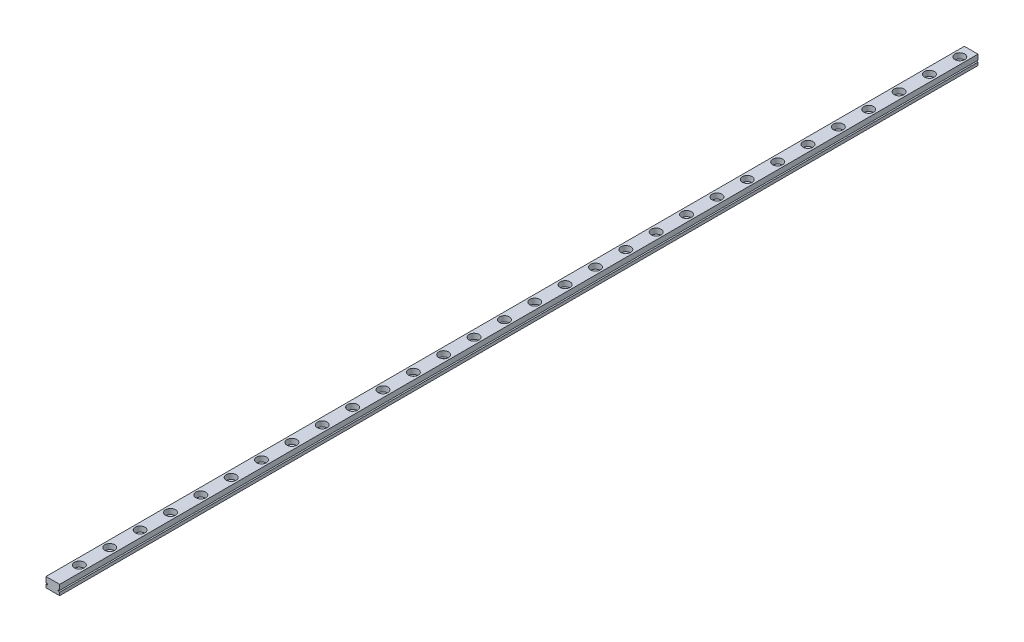
from build123d import *

# Parameters (mm, degrees)
SKETCH_1_W          = 9
SKETCH_1_H          = 6.5
EXTRUDE_1_DEPTH     = 608
SKETCH_2_R          = 1.75
CUT_EXTRUDE_1_DEPTH = 7.5
SKETCH_3_R          = 3.25
CUT_EXTRUDE_2_DEPTH = 3.5
CUT_EXTRUDE_3_DEPTH = 609
SKETCH_5_R          = 3.25
CUT_EXTRUDE_4_DEPTH = 3.5
SKETCH_6_R          = 1.75
CUT_EXTRUDE_5_DEPTH = 4
SKETCH_7_W          = 9
SKETCH_7_H          = 3
CUT_EXTRUDE_6_DEPTH = 7.5


with BuildPart() as part:
    # 草图1 → 凸台-拉伸1 (new body)
    with BuildSketch(Plane.XY):
        Rectangle(SKETCH_1_W, SKETCH_1_H)
    extrude(amount=EXTRUDE_1_DEPTH)

    # 草图2 → 切除-拉伸1 (cut, through all)
    with BuildSketch(Plane(origin=(0, 3.25, 0), x_dir=(1, 0, 0), z_dir=(0, 1, 0))):
        with Locations((0, -7.5)):
            Circle(SKETCH_2_R)
        with Locations((0, -27.5)):
            Circle(SKETCH_2_R)
        with Locations((0, -47.5)):
            Circle(SKETCH_2_R)
        with Locations((0, -67.5)):
            Circle(SKETCH_2_R)
        with Locations((0, -87.5)):
            Circle(SKETCH_2_R)
        with Locations((0, -107.5)):
            Circle(SKETCH_2_R)
        with Locations((0, -127.5)):
            Circle(SKETCH_2_R)
        with Locations((0, -147.5)):
            Circle(SKETCH_2_R)
        with Locations((0, -167.5)):
            Circle(SKETCH_2_R)
        with Locations((0, -187.5)):
            Circle(SKETCH_2_R)
        with Locations((0, -207.5)):
            Circle(SKETCH_2_R)
        with Locations((0, -227.5)):
            Circle(SKETCH_2_R)
        with Locations((0, -247.5)):
            Circle(SKETCH_2_R)
        with Locations((0, -267.5)):
            Circle(SKETCH_2_R)
        with Locations((0, -287.5)):
            Circle(SKETCH_2_R)
        with Locations((0, -307.5)):
            Circle(SKETCH_2_R)
        with Locations((0, -327.5)):
            Circle(SKETCH_2_R)
        with Locations((0, -347.5)):
            Circle(SKETCH_2_R)
        with Locations((0, -367.5)):
            Circle(SKETCH_2_R)
        with Locations((0, -387.5)):
            Circle(SKETCH_2_R)
    extrude(amount=-CUT_EXTRUDE_1_DEPTH, mode=Mode.SUBTRACT)

    # 草图3 → 切除-拉伸2 (cut)
    with BuildSketch(Plane(origin=(0, 3.25, 0), x_dir=(1, 0, 0), z_dir=(0, 1, 0))):
        with Locations((0, -7.5)):
            Circle(SKETCH_3_R)
        with Locations((0, -27.5)):
            Circle(SKETCH_3_R)
        with Locations((0, -47.5)):
            Circle(SKETCH_3_R)
        with Locations((0, -67.5)):
            Circle(SKETCH_3_R)
        with Locations((0, -87.5)):
            Circle(SKETCH_3_R)
        with Locations((0, -107.5)):
            Circle(SKETCH_3_R)
        with Locations((0, -127.5)):
            Circle(SKETCH_3_R)
        with Locations((0, -147.5)):
            Circle(SKETCH_3_R)
        with Locations((0, -167.5)):
            Circle(SKETCH_3_R)
        with Locations((0, -187.5)):
            Circle(SKETCH_3_R)
        with Locations((0, -207.5)):
            Circle(SKETCH_3_R)
        with Locations((0, -227.5)):
            Circle(SKETCH_3_R)
        with Locations((0, -247.5)):
            Circle(SKETCH_3_R)
        with Locations((0, -267.5)):
            Circle(SKETCH_3_R)
        with Locations((0, -287.5)):
            Circle(SKETCH_3_R)
        with Locations((0, -307.5)):
            Circle(SKETCH_3_R)
        with Locations((0, -327.5)):
            Circle(SKETCH_3_R)
        with Locations((0, -347.5)):
            Circle(SKETCH_3_R)
        with Locations((0, -367.5)):
            Circle(SKETCH_3_R)
        with Locations((0, -387.5)):
            Circle(SKETCH_3_R)
    extrude(amount=-CUT_EXTRUDE_2_DEPTH, mode=Mode.SUBTRACT)

    # 草图4 → 切除-拉伸3 (cut, through all)
    with BuildSketch(Plane(origin=(0, 0, 0), x_dir=(-1, 0, 0), z_dir=(0, 0, -1))):
        Polygon((4.5, -0.25), (3.5, -0.45), (3.5, -1.05), (4.5, -1.25), align=None)
        Polygon((-4.5, -0.25), (-3.5, -0.45), (-3.5, -1.05), (-4.5, -1.25), align=None)
    extrude(amount=-CUT_EXTRUDE_3_DEPTH, mode=Mode.SUBTRACT)

    # 草图5 → 切除-拉伸4 (cut)
    with BuildSketch(Plane(origin=(0, 3.25, 0), x_dir=(1, 0, 0), z_dir=(0, 1, 0))):
        with Locations((0, -407.5)):
            Circle(SKETCH_5_R)
        with Locations((0, -427.5)):
            Circle(SKETCH_5_R)
        with Locations((0, -447.5)):
            Circle(SKETCH_5_R)
        with Locations((0, -467.5)):
            Circle(SKETCH_5_R)
        with Locations((0, -487.5)):
            Circle(SKETCH_5_R)
        with Locations((0, -507.5)):
            Circle(SKETCH_5_R)
        with Locations((0, -527.5)):
            Circle(SKETCH_5_R)
        with Locations((0, -547.5)):
            Circle(SKETCH_5_R)
        with Locations((0, -567.5)):
            Circle(SKETCH_5_R)
        with Locations((0, -587.5)):
            Circle(SKETCH_5_R)
    extrude(amount=-CUT_EXTRUDE_4_DEPTH, mode=Mode.SUBTRACT)

    # 草图6 → 切除-拉伸5 (cut, through all)
    with BuildSketch(Plane(origin=(0, -0.25, 0), x_dir=(1, 0, 0), z_dir=(0, 1, 0))):
        with Locations((0, -407.5)):
            Circle(SKETCH_6_R)
        with Locations((0, -427.5)):
            Circle(SKETCH_6_R)
        with Locations((0, -447.5)):
            Circle(SKETCH_6_R)
        with Locations((0, -467.5)):
            Circle(SKETCH_6_R)
        with Locations((0, -487.5)):
            Circle(SKETCH_6_R)
        with Locations((0, -507.5)):
            Circle(SKETCH_6_R)
        with Locations((0, -527.5)):
            Circle(SKETCH_6_R)
        with Locations((0, -547.5)):
            Circle(SKETCH_6_R)
        with Locations((0, -567.5)):
            Circle(SKETCH_6_R)
        with Locations((0, -587.5)):
            Circle(SKETCH_6_R)
    extrude(amount=-CUT_EXTRUDE_5_DEPTH, mode=Mode.SUBTRACT)

    # 草图7 → 切除-拉伸6 (cut, through all)
    with BuildSketch(Plane(origin=(0, 3.25, 0), x_dir=(1, 0, 0), z_dir=(0, 1, 0))):
        with Locations((0, -606.5)):
            Rectangle(SKETCH_7_W, SKETCH_7_H)
    extrude(amount=-CUT_EXTRUDE_6_DEPTH, mode=Mode.SUBTRACT)


solid = part.part
